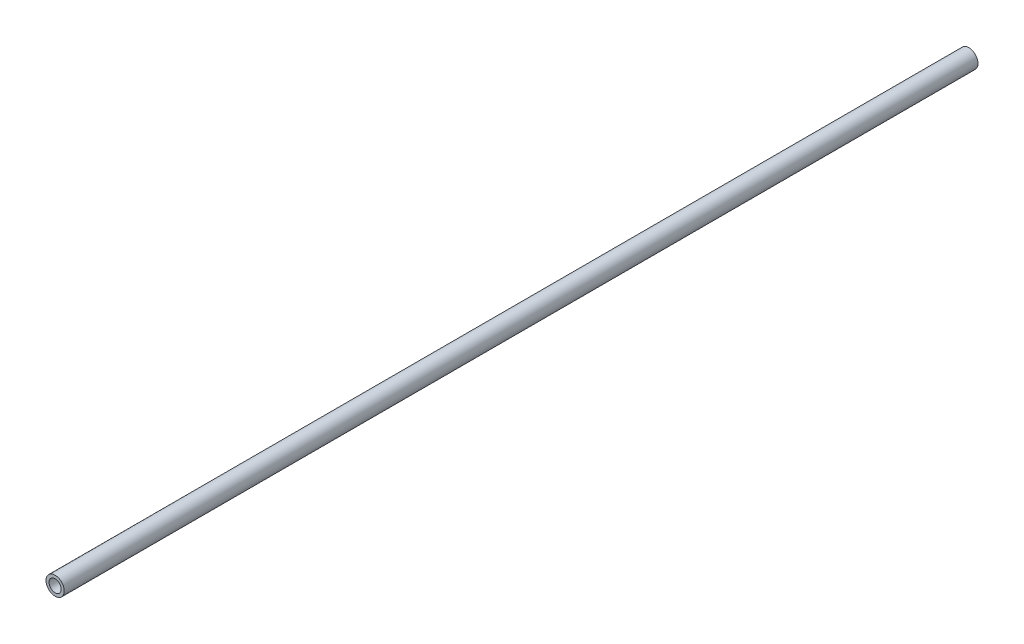
from build123d import *

# Parameters (mm, degrees)
SKETCH2_R           = 7.62
SKETCH2_R_2         = 5.08
BOSS_EXTRUDE1_DEPTH = 762


with BuildPart() as part:
    # Sketch2 → Boss-Extrude1 (new body)
    with BuildSketch(Plane.XY):
        Circle(SKETCH2_R)
        Circle(SKETCH2_R_2, mode=Mode.SUBTRACT)
    extrude(amount=BOSS_EXTRUDE1_DEPTH)


solid = part.part
